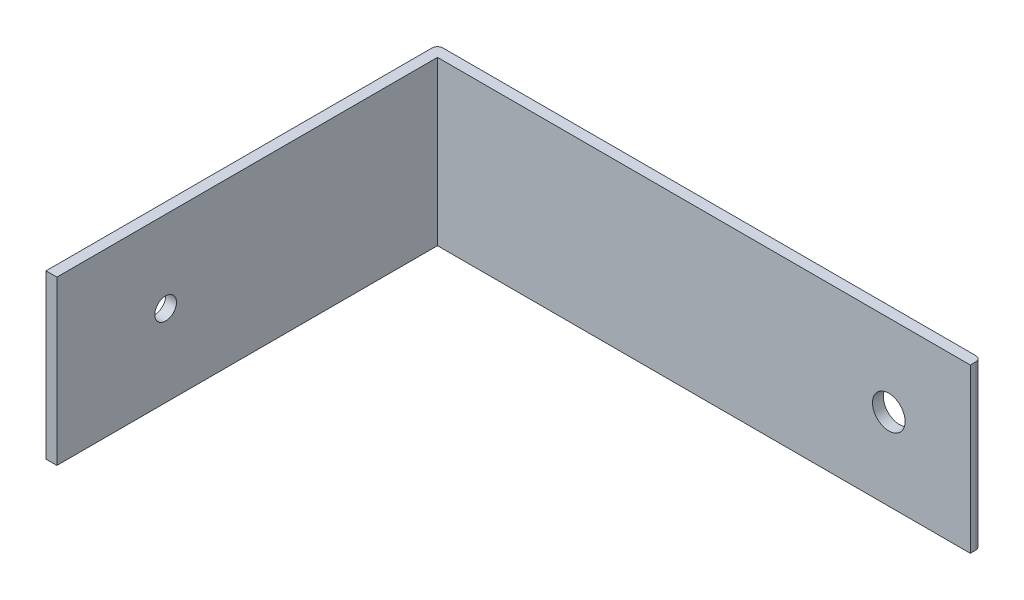
from build123d import *

# Parameters (mm, degrees)
ESQUISSE1_W             = 100
ESQUISSE1_H             = 30
BOSS_EXTRU_1_DEPTH      = 2
ESQUISSE2_W             = 2
ESQUISSE2_H             = 30
BOSS_EXTRU_2_DEPTH      = 70
ESQUISSE4_R             = 2
ENL_V_MAT_EXTRU_1_DEPTH = 101
CONG_1_R                = 1
CONG_2_R                = 1
ESQUISSE5_R             = 3
ENL_V_MAT_EXTRU_2_DEPTH = 10


with BuildPart() as part:
    # Esquisse1 → Boss.-Extru.1 (new body)
    with BuildSketch(Plane.XY):
        with Locations((50, -15)):
            Rectangle(ESQUISSE1_W, ESQUISSE1_H)
    extrude(amount=BOSS_EXTRU_1_DEPTH)

    # Esquisse2 → Boss.-Extru.2 (add)
    with BuildSketch(Plane.XY.offset(2)):
        with Locations((1, -15)):
            Rectangle(ESQUISSE2_W, ESQUISSE2_H)
    extrude(amount=BOSS_EXTRU_2_DEPTH)

    # Esquisse4 → Enlèv. mat.-Extru.1 (cut, through all)
    with BuildSketch(Plane.ZY):
        with Locations((52, -15)):
            Circle(ESQUISSE4_R)
    extrude(amount=-ENL_V_MAT_EXTRU_1_DEPTH, mode=Mode.SUBTRACT)

    # Congé1
    cong_1_edges = [part.edges().sort_by_distance(p)[0] for p in [
        (0, -15, 0),
    ]]
    fillet(cong_1_edges, radius=CONG_1_R)

    # Congé2
    cong_2_edges = [part.edges().sort_by_distance(p)[0] for p in [
        (100, -15, 0),
    ]]
    fillet(cong_2_edges, radius=CONG_2_R)

    # Esquisse5 → Enlèv. mat.-Extru.2 (cut)
    with BuildSketch(Plane(origin=(0, 0, 0), x_dir=(-1, 0, 0), z_dir=(0, 0, -1))):
        with Locations((-85, -15)):
            Circle(ESQUISSE5_R)
    extrude(amount=-ENL_V_MAT_EXTRU_2_DEPTH, mode=Mode.SUBTRACT)


solid = part.part
